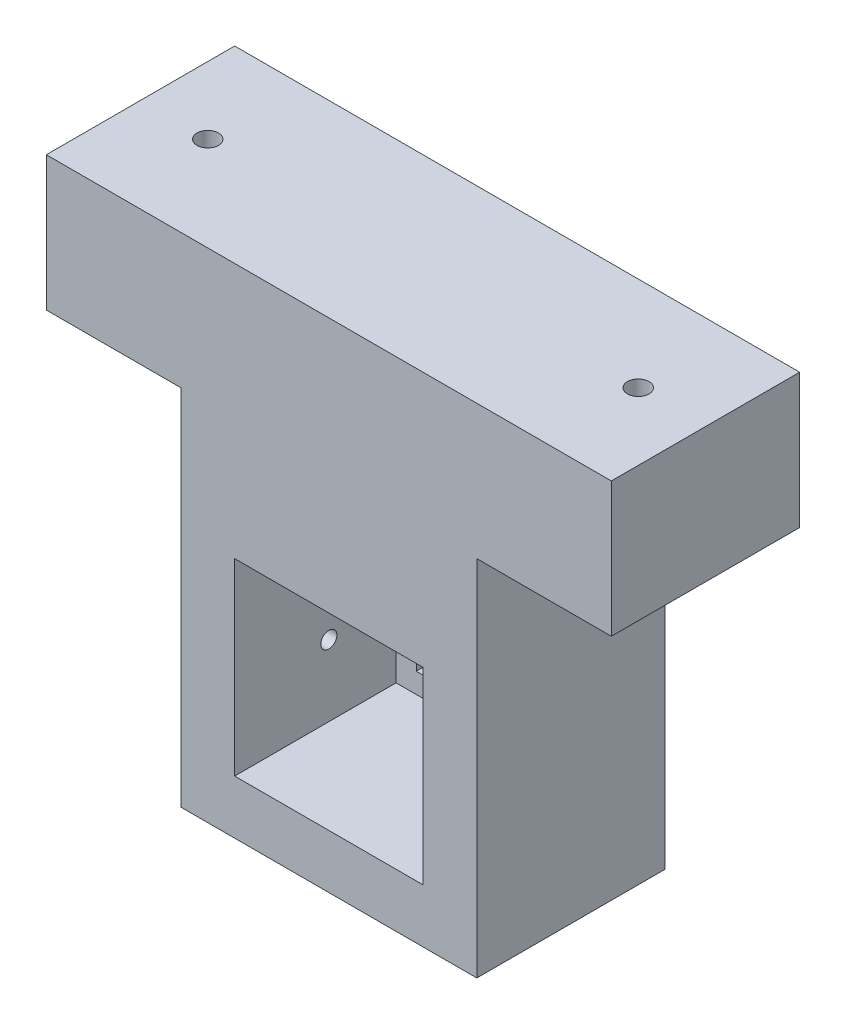
from build123d import *

# Parameters (mm, degrees)
ESQUISSE1_W             = 11
ESQUISSE1_H             = 18.5
BOSS_EXTRU_1_DEPTH      = 7
ESQUISSE2_W             = 7
ESQUISSE2_H             = 7
ENL_V_MAT_EXTRU_1_DEPTH = 6
ESQUISSE4_W             = 5.5
ESQUISSE4_H             = 5.5
ENL_V_MAT_EXTRU_2_DEPTH = 10
ENL_V_MAT_EXTRU_3_REACH = 13
ESQUISSE5_R             = 0.3
ESQUISSE7_W             = 7
ESQUISSE7_H             = 5
BOSS_EXTRU_2_DEPTH      = 5
ESQUISSE8_W             = 7
ESQUISSE8_H             = 5
BOSS_EXTRU_3_DEPTH      = 5
ESQUISSE9_R             = 0.4
ENL_V_MAT_EXTRU_4_DEPTH = 19.5


with BuildPart() as part:
    # Esquisse1 → Boss.-Extru.1 (new body)
    with BuildSketch(Plane.XY):
        with Locations((5.5, 9.25)):
            Rectangle(ESQUISSE1_W, ESQUISSE1_H)
    extrude(amount=BOSS_EXTRU_1_DEPTH)

    # Esquisse2 → Enlèv. mat.-Extru.1 (cut)
    with BuildSketch(Plane.XY.offset(7)):
        with Locations((5.5, 5.5)):
            Rectangle(ESQUISSE2_W, ESQUISSE2_H)
    extrude(amount=-ENL_V_MAT_EXTRU_1_DEPTH, mode=Mode.SUBTRACT)

    # Esquisse4 → Enlèv. mat.-Extru.2 (cut)
    with BuildSketch(Plane.XY.offset(1)):
        with Locations((5.5, 5.5)):
            Rectangle(ESQUISSE4_W, ESQUISSE4_H)
    extrude(amount=-ENL_V_MAT_EXTRU_2_DEPTH, mode=Mode.SUBTRACT)

    # Esquisse5 → Enlèv. mat.-Extru.3 (cut, up to next)
    with BuildSketch(Plane.ZY, mode=Mode.PRIVATE) as enl_v_mat_extru_3_sk1:
        with Locations((3.5, 4.640028524)):
            Circle(ESQUISSE5_R)
    enl_v_mat_extru_3_tool1 = extrude(enl_v_mat_extru_3_sk1.sketch, amount=-ENL_V_MAT_EXTRU_3_REACH, mode=Mode.PRIVATE) & part.part
    add(enl_v_mat_extru_3_tool1.solids().sort_by_distance((0, 4.640029, 3.5))[0], mode=Mode.SUBTRACT)

    # Esquisse7 → Boss.-Extru.2 (add)
    with BuildSketch(Plane(origin=(11, 0, 0), x_dir=(0, 0, -1), z_dir=(1, 0, 0))):
        with Locations((-3.5, 16)):
            Rectangle(ESQUISSE7_W, ESQUISSE7_H)
    extrude(amount=BOSS_EXTRU_2_DEPTH)

    # Esquisse8 → Boss.-Extru.3 (add)
    with BuildSketch(Plane.ZY):
        with Locations((3.5, 16)):
            Rectangle(ESQUISSE8_W, ESQUISSE8_H)
    extrude(amount=BOSS_EXTRU_3_DEPTH)

    # Esquisse9 → Enlèv. mat.-Extru.4 (cut, through all)
    with BuildSketch(Plane(origin=(0, 18.5, 0), x_dir=(1, 0, 0), z_dir=(0, 1, 0))):
        with Locations((-2.5, -3.5)):
            Circle(ESQUISSE9_R)
        with Locations((13.5, -3.5)):
            Circle(ESQUISSE9_R)
    extrude(amount=-ENL_V_MAT_EXTRU_4_DEPTH, mode=Mode.SUBTRACT)


solid = part.part
